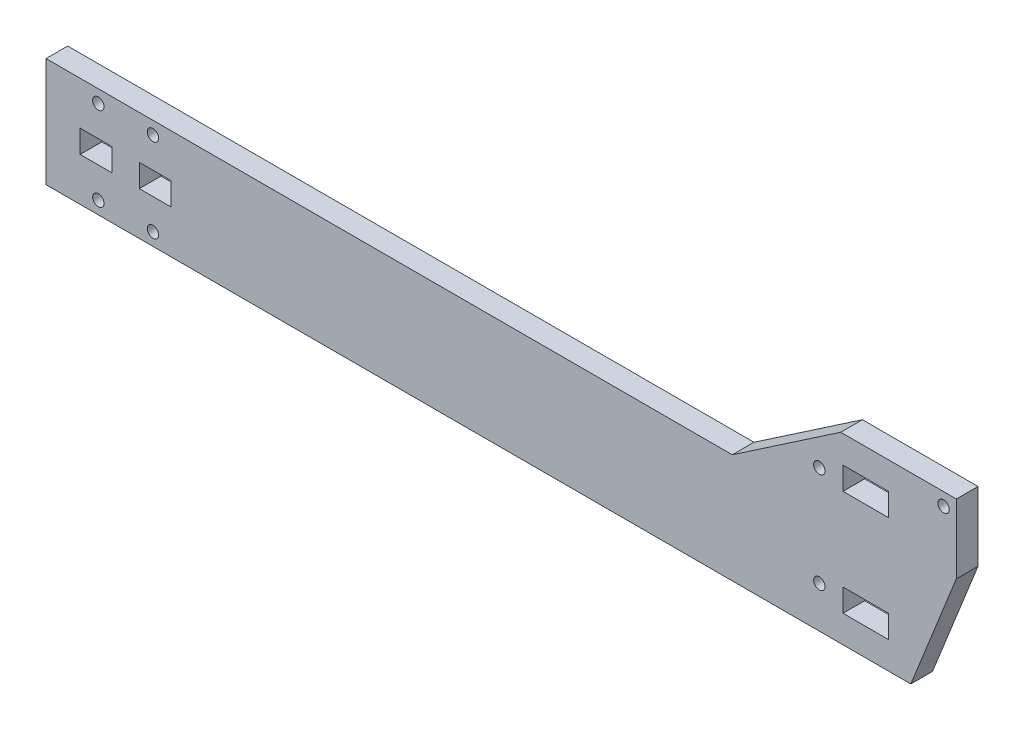
from build123d import *

# Parameters (mm, degrees)
BOSS_EXTRUDE1_DEPTH = 4.7625
SKETCH2_R           = 1.25
SKETCH2_W           = 10
SKETCH2_H           = 5
SKETCH2_W_2         = 7
CUT_EXTRUDE1_DEPTH  = 5.7625


with BuildPart() as part:
    # Sketch1 → Boss-Extrude1 (new body)
    with BuildSketch(Plane.XY):
        Polygon((174.6, 40.2), (150.776470588, 24), (0, 24), (0, 0), (190, 0), (200, 25), (200, 40.2), align=None)
    extrude(amount=BOSS_EXTRUDE1_DEPTH)

    # Sketch2 → Cut-Extrude1 (cut, through all)
    with BuildSketch(Plane.XY.offset(4.7625)):
        with Locations((169.9, 31.1)):
            Circle(SKETCH2_R)
        with Locations((197.2, 37.4)):
            Circle(SKETCH2_R)
        with Locations((169.9, 9.1)):
            Circle(SKETCH2_R)
        with Locations((23.5, 21.2)):
            Circle(SKETCH2_R)
        with Locations((11.5, 21.2)):
            Circle(SKETCH2_R)
        with Locations((11.5, 2.8)):
            Circle(SKETCH2_R)
        with Locations((23.5, 2.8)):
            Circle(SKETCH2_R)
        with Locations((180.1, 31.7)):
            Rectangle(SKETCH2_W, SKETCH2_H)
        with Locations((180.1, 8.5)):
            Rectangle(SKETCH2_W, SKETCH2_H)
        with Locations((11, 12)):
            Rectangle(SKETCH2_W_2, SKETCH2_H)
        with Locations((24, 12)):
            Rectangle(SKETCH2_W_2, SKETCH2_H)
    extrude(amount=-CUT_EXTRUDE1_DEPTH, mode=Mode.SUBTRACT)


solid = part.part
